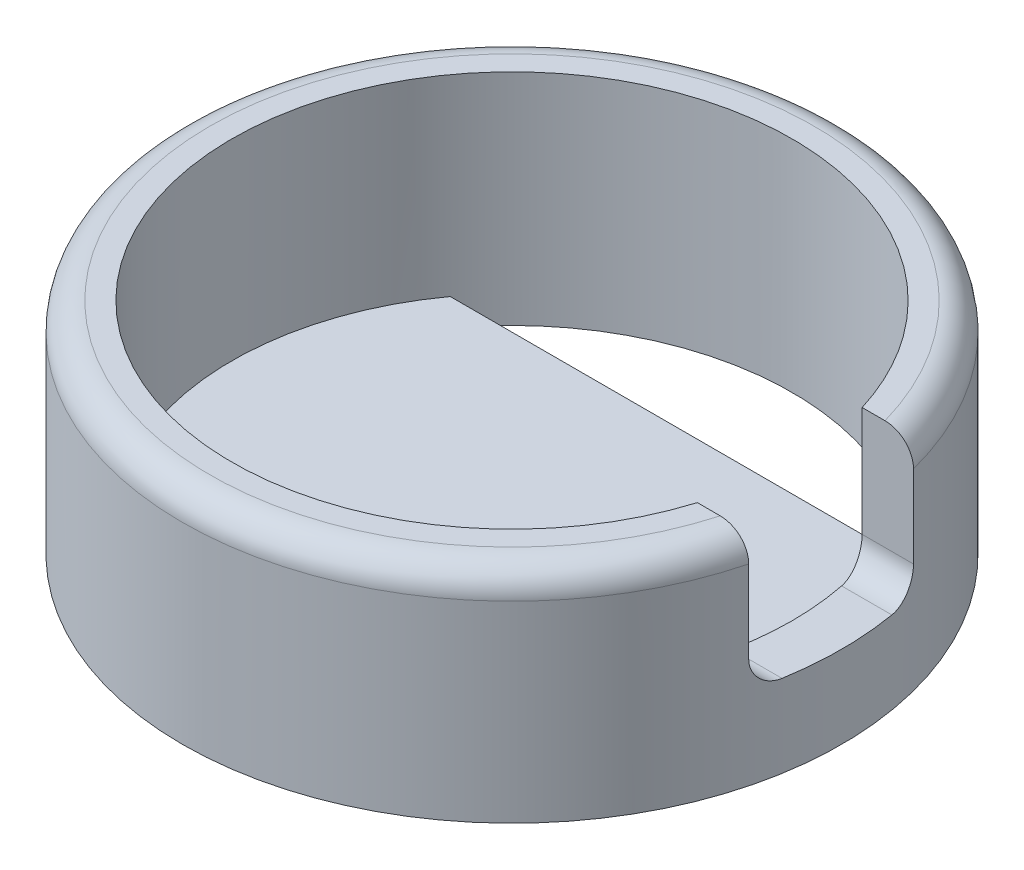
from build123d import *

# Parameters (mm, degrees)
SKETCH1_R           = 6
SKETCH1_R_2         = 5.1
BOSS_EXTRUDE1_DEPTH = 3.5
SKETCH4_R           = 6
BOSS_EXTRUDE2_DEPTH = 0.5
SKETCH5_W           = 6
SKETCH5_H           = 3
CUT_EXTRUDE3_DEPTH  = 2.5
CUT_EXTRUDE4_DEPTH  = 1.5
FILLET1_R           = 0.5


with BuildPart() as part:
    # Sketch1 → Boss-Extrude1 (new body)
    with BuildSketch(Plane(origin=(0, 0, 0), x_dir=(1, 0, 0), z_dir=(0, 1, 0))):
        Circle(SKETCH1_R)
        Circle(SKETCH1_R_2, mode=Mode.SUBTRACT)
    extrude(amount=BOSS_EXTRUDE1_DEPTH)

    # Sketch4 → Boss-Extrude2 (add)
    with BuildSketch(Plane.XZ):
        Circle(SKETCH4_R)
    extrude(amount=BOSS_EXTRUDE2_DEPTH)

    # Sketch5 → Cut-Extrude3 (cut)
    with BuildSketch(Plane.XZ.offset(-3.5)):
        with Locations((3, 0)):
            Rectangle(SKETCH5_W, SKETCH5_H)
    extrude(amount=CUT_EXTRUDE3_DEPTH, mode=Mode.SUBTRACT)

    # Sketch7 → Cut-Extrude4 (cut, through all)
    with BuildSketch(Plane(origin=(0, 0, 0), x_dir=(1, 0, 0), z_dir=(0, 1, 0))):
        with BuildLine():
            Line((4.124318125, -3), (-4.124318125, -3))
            ThreePointArc((-4.124318125, -3), (0, -5.1), (4.124318125, -3))
        make_face()
        with BuildLine():
            Line((4.124318125, 3), (-4.124318125, 3))
            ThreePointArc((-4.124318125, 3), (0, 5.1), (4.124318125, 3))
        make_face()
    extrude(amount=-CUT_EXTRUDE4_DEPTH, mode=Mode.SUBTRACT)

    # Fillet1
    fillet1_edges = [part.edges().sort_by_distance(p)[0] for p in [
        (-6, 3.5, 0),
        (5.341949031, 1, -1.5),
        (5.341949031, 1, 1.5),
    ]]
    fillet(fillet1_edges, radius=FILLET1_R)


solid = part.part
